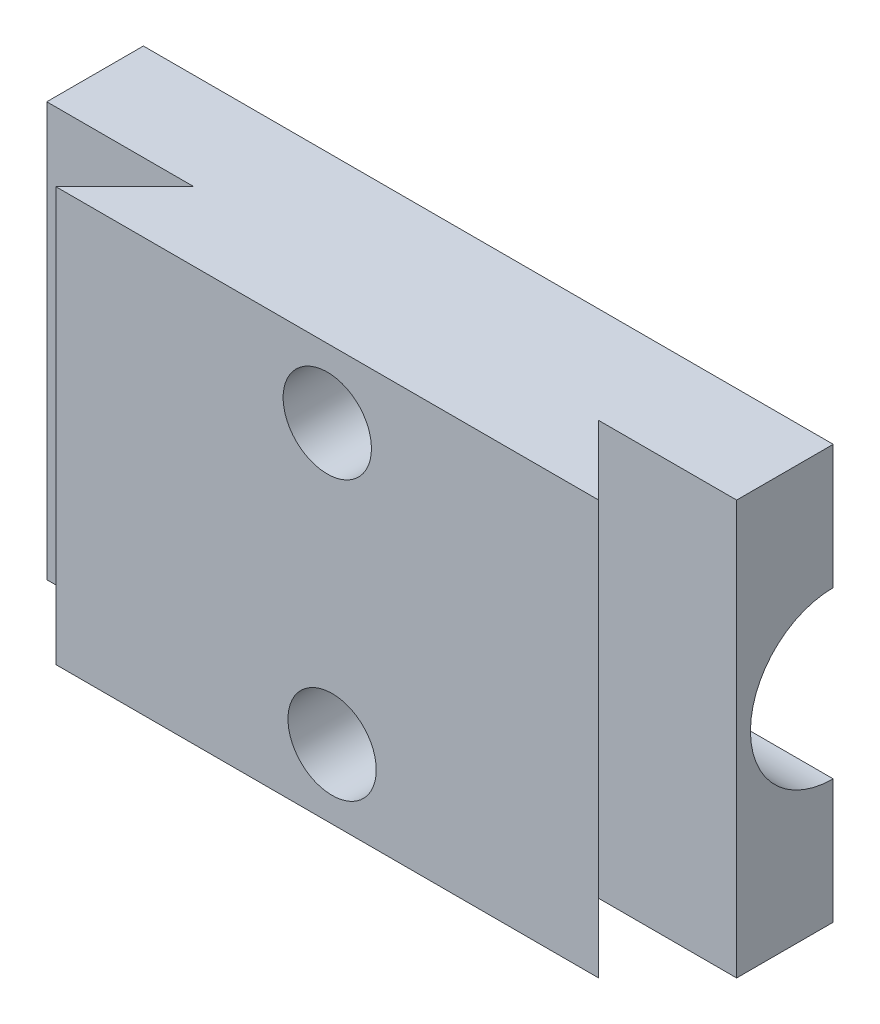
from build123d import *

# Parameters (mm, degrees)
SKETCH_1_W            = 50
SKETCH_1_H            = 30
EXTRUDE_320_DEPTH     = 5
CUT_EXTRUDE_710_DEPTH = 59.523499554
SKETCH_8_W            = 50
SKETCH_8_H            = 30
EXTRUDE_1_DEPTH       = 2
SKETCH_11_R           = 6
CUT_EXTRUDE_2_DEPTH   = 59.72818744
SKETCH_12_R           = 1.5
CUT_EXTRUDE_3_DEPTH   = 60.531504265
SKETCH_12_3_R         = 3.2
CUT_EXTRUDE_4_DEPTH   = 5


with BuildPart() as part:
    # Эскиз1 → Extrude 320 (new, symmetric)
    with BuildSketch(Plane.XY):
        with Locations((25, 15)):
            Rectangle(SKETCH_1_W, SKETCH_1_H)
    extrude(amount=EXTRUDE_320_DEPTH, both=True)

    # Эскиз2 → Cut-Extrude 710 (cut, through all)
    with BuildSketch(Plane(origin=(0, 30, 0), x_dir=(1, 0, 0), z_dir=(0, 1, 0))):
        Polygon((40, 0), (45, -5), (50, -5), (50, 0), align=None)
        Polygon((10.662267101, 0), (0, 0), (0, -5), (5.662267101, -5), align=None)
    extrude(amount=-CUT_EXTRUDE_710_DEPTH, mode=Mode.SUBTRACT)

    # Эскиз8 → Бобышка-Вытянуть1 (add)
    with BuildSketch(Plane(origin=(0, 0, -5), x_dir=(-1, 0, 0), z_dir=(0, 0, -1))):
        with Locations((-25, 15)):
            Rectangle(SKETCH_8_W, SKETCH_8_H)
    extrude(amount=EXTRUDE_1_DEPTH)

    # Эскиз11 → Вырез-Вытянуть2 (cut, through all)
    with BuildSketch(Plane.ZY):
        with Locations((-7, 15)):
            Circle(SKETCH_11_R)
    extrude(amount=-CUT_EXTRUDE_2_DEPTH, mode=Mode.SUBTRACT)

    # Эскиз12 → Вырез-Вытянуть3 (cut, through all)
    with BuildSketch(Plane.XY.offset(5)):
        with Locations((25.679943924, 5)):
            Circle(SKETCH_12_R)
        with Locations((25.331133551, 25)):
            Circle(SKETCH_12_R)
    extrude(amount=-CUT_EXTRUDE_3_DEPTH, mode=Mode.SUBTRACT)

    # Эскиз12<3> → Вырез-Вытянуть4 (cut)
    with BuildSketch(Plane.XY.offset(5)):
        with Locations((25.331133551, 25)):
            Circle(SKETCH_12_3_R)
        with Locations((25.679943924, 5)):
            Circle(SKETCH_12_3_R)
    extrude(amount=-CUT_EXTRUDE_4_DEPTH, mode=Mode.SUBTRACT)


solid = part.part
